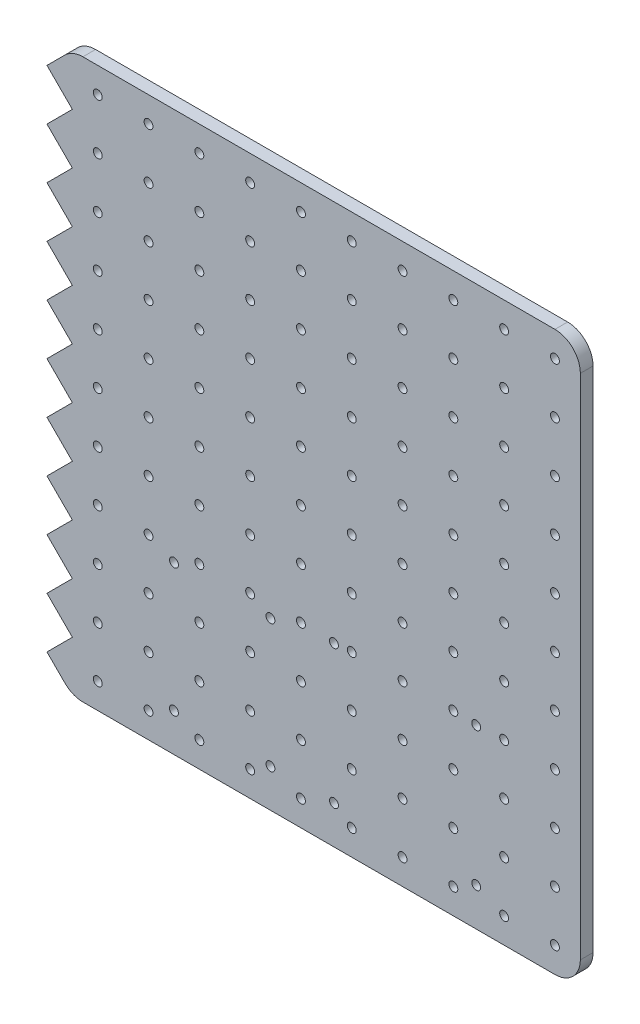
from build123d import *

# Parameters (mm, degrees)
SKETCH1_R           = 1.75
BOSS_EXTRUDE1_DEPTH = 5
FILLET1_R           = 10


with BuildPart() as part:
    # Sketch1 → Boss-Extrude1 (new body)
    with BuildSketch(Plane.XY):
        Polygon((0, 0), (-10, 10), (0, 20), (-10, 30), (0, 40), (-10, 50), (0, 60), (-10, 70), (0, 80), (-10, 90), (0, 100), (-10, 110), (0, 120), (-10, 130), (0, 140), (-10, 150), (0, 160), (-10, 170), (0, 180), (-10, 190), (0, 200), (-10, 210), (0, 220), (200, 220), (200, 0), align=None)
        with Locations((190, 210)):
            Circle(SKETCH1_R, mode=Mode.SUBTRACT)
        with Locations((190, 190)):
            Circle(SKETCH1_R, mode=Mode.SUBTRACT)
        with Locations((190, 170)):
            Circle(SKETCH1_R, mode=Mode.SUBTRACT)
        with Locations((190, 150)):
            Circle(SKETCH1_R, mode=Mode.SUBTRACT)
        with Locations((190, 130)):
            Circle(SKETCH1_R, mode=Mode.SUBTRACT)
        with Locations((190, 110)):
            Circle(SKETCH1_R, mode=Mode.SUBTRACT)
        with Locations((190, 90)):
            Circle(SKETCH1_R, mode=Mode.SUBTRACT)
        with Locations((190, 70)):
            Circle(SKETCH1_R, mode=Mode.SUBTRACT)
        with Locations((190, 50)):
            Circle(SKETCH1_R, mode=Mode.SUBTRACT)
        with Locations((190, 30)):
            Circle(SKETCH1_R, mode=Mode.SUBTRACT)
        with Locations((190, 10)):
            Circle(SKETCH1_R, mode=Mode.SUBTRACT)
        with Locations((170, 210)):
            Circle(SKETCH1_R, mode=Mode.SUBTRACT)
        with Locations((170, 190)):
            Circle(SKETCH1_R, mode=Mode.SUBTRACT)
        with Locations((170, 170)):
            Circle(SKETCH1_R, mode=Mode.SUBTRACT)
        with Locations((170, 150)):
            Circle(SKETCH1_R, mode=Mode.SUBTRACT)
        with Locations((170, 130)):
            Circle(SKETCH1_R, mode=Mode.SUBTRACT)
        with Locations((150, 130)):
            Circle(SKETCH1_R, mode=Mode.SUBTRACT)
        with Locations((150, 150)):
            Circle(SKETCH1_R, mode=Mode.SUBTRACT)
        with Locations((150, 170)):
            Circle(SKETCH1_R, mode=Mode.SUBTRACT)
        with Locations((150, 190)):
            Circle(SKETCH1_R, mode=Mode.SUBTRACT)
        with Locations((150, 210)):
            Circle(SKETCH1_R, mode=Mode.SUBTRACT)
        with Locations((130, 210)):
            Circle(SKETCH1_R, mode=Mode.SUBTRACT)
        with Locations((130, 190)):
            Circle(SKETCH1_R, mode=Mode.SUBTRACT)
        with Locations((130, 170)):
            Circle(SKETCH1_R, mode=Mode.SUBTRACT)
        with Locations((130, 150)):
            Circle(SKETCH1_R, mode=Mode.SUBTRACT)
        with Locations((130, 130)):
            Circle(SKETCH1_R, mode=Mode.SUBTRACT)
        with Locations((110, 130)):
            Circle(SKETCH1_R, mode=Mode.SUBTRACT)
        with Locations((110, 150)):
            Circle(SKETCH1_R, mode=Mode.SUBTRACT)
        with Locations((110, 170)):
            Circle(SKETCH1_R, mode=Mode.SUBTRACT)
        with Locations((110, 190)):
            Circle(SKETCH1_R, mode=Mode.SUBTRACT)
        with Locations((110, 210)):
            Circle(SKETCH1_R, mode=Mode.SUBTRACT)
        with Locations((90, 210)):
            Circle(SKETCH1_R, mode=Mode.SUBTRACT)
        with Locations((90, 190)):
            Circle(SKETCH1_R, mode=Mode.SUBTRACT)
        with Locations((90, 170)):
            Circle(SKETCH1_R, mode=Mode.SUBTRACT)
        with Locations((90, 150)):
            Circle(SKETCH1_R, mode=Mode.SUBTRACT)
        with Locations((90, 130)):
            Circle(SKETCH1_R, mode=Mode.SUBTRACT)
        with Locations((70, 130)):
            Circle(SKETCH1_R, mode=Mode.SUBTRACT)
        with Locations((70, 150)):
            Circle(SKETCH1_R, mode=Mode.SUBTRACT)
        with Locations((70, 170)):
            Circle(SKETCH1_R, mode=Mode.SUBTRACT)
        with Locations((70, 190)):
            Circle(SKETCH1_R, mode=Mode.SUBTRACT)
        with Locations((70, 210)):
            Circle(SKETCH1_R, mode=Mode.SUBTRACT)
        with Locations((50, 210)):
            Circle(SKETCH1_R, mode=Mode.SUBTRACT)
        with Locations((50, 190)):
            Circle(SKETCH1_R, mode=Mode.SUBTRACT)
        with Locations((50, 170)):
            Circle(SKETCH1_R, mode=Mode.SUBTRACT)
        with Locations((50, 150)):
            Circle(SKETCH1_R, mode=Mode.SUBTRACT)
        with Locations((50, 130)):
            Circle(SKETCH1_R, mode=Mode.SUBTRACT)
        with Locations((30, 130)):
            Circle(SKETCH1_R, mode=Mode.SUBTRACT)
        with Locations((30, 150)):
            Circle(SKETCH1_R, mode=Mode.SUBTRACT)
        with Locations((30, 170)):
            Circle(SKETCH1_R, mode=Mode.SUBTRACT)
        with Locations((30, 190)):
            Circle(SKETCH1_R, mode=Mode.SUBTRACT)
        with Locations((30, 210)):
            Circle(SKETCH1_R, mode=Mode.SUBTRACT)
        with Locations((10, 210)):
            Circle(SKETCH1_R, mode=Mode.SUBTRACT)
        with Locations((10, 190)):
            Circle(SKETCH1_R, mode=Mode.SUBTRACT)
        with Locations((10, 170)):
            Circle(SKETCH1_R, mode=Mode.SUBTRACT)
        with Locations((10, 150)):
            Circle(SKETCH1_R, mode=Mode.SUBTRACT)
        with Locations((10, 130)):
            Circle(SKETCH1_R, mode=Mode.SUBTRACT)
        with Locations((10, 10)):
            Circle(SKETCH1_R, mode=Mode.SUBTRACT)
        with Locations((10, 30)):
            Circle(SKETCH1_R, mode=Mode.SUBTRACT)
        with Locations((10, 50)):
            Circle(SKETCH1_R, mode=Mode.SUBTRACT)
        with Locations((10, 70)):
            Circle(SKETCH1_R, mode=Mode.SUBTRACT)
        with Locations((10, 90)):
            Circle(SKETCH1_R, mode=Mode.SUBTRACT)
        with Locations((10, 110)):
            Circle(SKETCH1_R, mode=Mode.SUBTRACT)
        with Locations((30, 110)):
            Circle(SKETCH1_R, mode=Mode.SUBTRACT)
        with Locations((30, 90)):
            Circle(SKETCH1_R, mode=Mode.SUBTRACT)
        with Locations((30, 70)):
            Circle(SKETCH1_R, mode=Mode.SUBTRACT)
        with Locations((30, 50)):
            Circle(SKETCH1_R, mode=Mode.SUBTRACT)
        with Locations((30, 30)):
            Circle(SKETCH1_R, mode=Mode.SUBTRACT)
        with Locations((30, 10)):
            Circle(SKETCH1_R, mode=Mode.SUBTRACT)
        with Locations((50, 10)):
            Circle(SKETCH1_R, mode=Mode.SUBTRACT)
        with Locations((70, 10)):
            Circle(SKETCH1_R, mode=Mode.SUBTRACT)
        with Locations((70, 30)):
            Circle(SKETCH1_R, mode=Mode.SUBTRACT)
        with Locations((50, 30)):
            Circle(SKETCH1_R, mode=Mode.SUBTRACT)
        with Locations((50, 50)):
            Circle(SKETCH1_R, mode=Mode.SUBTRACT)
        with Locations((50, 70)):
            Circle(SKETCH1_R, mode=Mode.SUBTRACT)
        with Locations((50, 90)):
            Circle(SKETCH1_R, mode=Mode.SUBTRACT)
        with Locations((50, 110)):
            Circle(SKETCH1_R, mode=Mode.SUBTRACT)
        with Locations((70, 110)):
            Circle(SKETCH1_R, mode=Mode.SUBTRACT)
        with Locations((70, 90)):
            Circle(SKETCH1_R, mode=Mode.SUBTRACT)
        with Locations((70, 70)):
            Circle(SKETCH1_R, mode=Mode.SUBTRACT)
        with Locations((70, 50)):
            Circle(SKETCH1_R, mode=Mode.SUBTRACT)
        with Locations((90, 10)):
            Circle(SKETCH1_R, mode=Mode.SUBTRACT)
        with Locations((90, 30)):
            Circle(SKETCH1_R, mode=Mode.SUBTRACT)
        with Locations((90, 50)):
            Circle(SKETCH1_R, mode=Mode.SUBTRACT)
        with Locations((90, 70)):
            Circle(SKETCH1_R, mode=Mode.SUBTRACT)
        with Locations((90, 90)):
            Circle(SKETCH1_R, mode=Mode.SUBTRACT)
        with Locations((110, 90)):
            Circle(SKETCH1_R, mode=Mode.SUBTRACT)
        with Locations((90, 110)):
            Circle(SKETCH1_R, mode=Mode.SUBTRACT)
        with Locations((110, 110)):
            Circle(SKETCH1_R, mode=Mode.SUBTRACT)
        with Locations((130, 110)):
            Circle(SKETCH1_R, mode=Mode.SUBTRACT)
        with Locations((150, 110)):
            Circle(SKETCH1_R, mode=Mode.SUBTRACT)
        with Locations((170, 110)):
            Circle(SKETCH1_R, mode=Mode.SUBTRACT)
        with Locations((170, 90)):
            Circle(SKETCH1_R, mode=Mode.SUBTRACT)
        with Locations((150, 90)):
            Circle(SKETCH1_R, mode=Mode.SUBTRACT)
        with Locations((130, 90)):
            Circle(SKETCH1_R, mode=Mode.SUBTRACT)
        with Locations((110, 70)):
            Circle(SKETCH1_R, mode=Mode.SUBTRACT)
        with Locations((130, 70)):
            Circle(SKETCH1_R, mode=Mode.SUBTRACT)
        with Locations((150, 70)):
            Circle(SKETCH1_R, mode=Mode.SUBTRACT)
        with Locations((170, 70)):
            Circle(SKETCH1_R, mode=Mode.SUBTRACT)
        with Locations((170, 50)):
            Circle(SKETCH1_R, mode=Mode.SUBTRACT)
        with Locations((150, 50)):
            Circle(SKETCH1_R, mode=Mode.SUBTRACT)
        with Locations((130, 50)):
            Circle(SKETCH1_R, mode=Mode.SUBTRACT)
        with Locations((110, 50)):
            Circle(SKETCH1_R, mode=Mode.SUBTRACT)
        with Locations((110, 30)):
            Circle(SKETCH1_R, mode=Mode.SUBTRACT)
        with Locations((110, 10)):
            Circle(SKETCH1_R, mode=Mode.SUBTRACT)
        with Locations((130, 10)):
            Circle(SKETCH1_R, mode=Mode.SUBTRACT)
        with Locations((130, 30)):
            Circle(SKETCH1_R, mode=Mode.SUBTRACT)
        with Locations((150, 10)):
            Circle(SKETCH1_R, mode=Mode.SUBTRACT)
        with Locations((150, 30)):
            Circle(SKETCH1_R, mode=Mode.SUBTRACT)
        with Locations((170, 10)):
            Circle(SKETCH1_R, mode=Mode.SUBTRACT)
        with Locations((170, 30)):
            Circle(SKETCH1_R, mode=Mode.SUBTRACT)
        with Locations((40, 65.5)):
            Circle(SKETCH1_R, mode=Mode.SUBTRACT)
        with Locations((40, 15)):
            Circle(SKETCH1_R, mode=Mode.SUBTRACT)
        with Locations((78, 15)):
            Circle(SKETCH1_R, mode=Mode.SUBTRACT)
        with Locations((78, 65.5)):
            Circle(SKETCH1_R, mode=Mode.SUBTRACT)
        with Locations((103, 69.5)):
            Circle(SKETCH1_R, mode=Mode.SUBTRACT)
        with Locations((103, 15)):
            Circle(SKETCH1_R, mode=Mode.SUBTRACT)
        with Locations((159, 15)):
            Circle(SKETCH1_R, mode=Mode.SUBTRACT)
        with Locations((159, 69.5)):
            Circle(SKETCH1_R, mode=Mode.SUBTRACT)
    extrude(amount=BOSS_EXTRUDE1_DEPTH)

    # Fillet1
    fillet1_edges = [part.edges().sort_by_distance(p)[0] for p in [
        (0, 0, 2.5),
        (0, 220, 2.5),
        (200, 220, 2.5),
        (200, 0, 2.5),
    ]]
    fillet(fillet1_edges, radius=FILLET1_R)


solid = part.part
